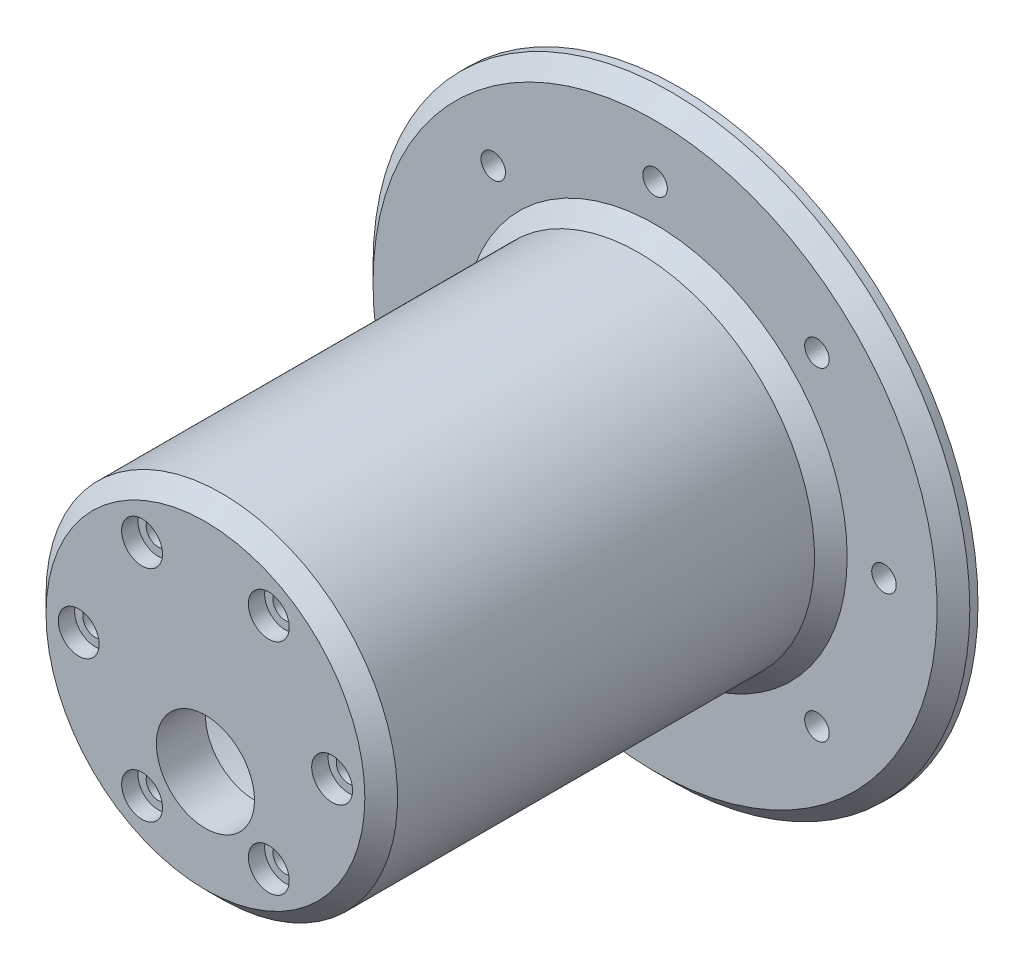
from build123d import *

# Parameters (mm, degrees)
CBORE_FOR_M1_6_HEX_HEAD_CAP_SCREW1_D           = 3
CBORE_FOR_M1_6_HEX_HEAD_CAP_SCREW1_CBORE_D     = 5
CBORE_FOR_M1_6_HEX_HEAD_CAP_SCREW1_CBORE_DEPTH = 2
CIRPATTERN1_COUNT                              = 6
F_12_0MM_DOWEL_HOLE1_D                         = 12
F_12_0MM_DOWEL_HOLE1_DEPTH                     = 15
F_12_0MM_DOWEL_HOLE1_TIP                       = 3.605163714
CHAMFER1_SIZE                                  = 2
CIRPATTERN2_COUNT                              = 8


with BuildPart() as part:
    # Sketch1 → Revolve1 (revolve)
    with BuildSketch(Plane(origin=(0, 0, 0), x_dir=(0, 0, -1), z_dir=(1, 0, 0))):
        Polygon((0, 0), (0, 18.5), (52, 18.5), (52, 23.5), (51, 23.5), (51, 25.5), (52, 25.5), (52, 36.5), (49, 36.5), (49, 21.5), (-6, 21.5), (-6, 0), align=None)
    revolve(axis=Axis((0, 0, 6), (0, 0, -1)))

    # CBORE for M1.6 Hex Head Cap Screw1 (through all)
    with Locations(Plane.XY.offset(6)):
        with Locations((15.5, 0)):
            cbore_for_m1_6_hex_head_cap_screw1 = CounterBoreHole(CBORE_FOR_M1_6_HEX_HEAD_CAP_SCREW1_D / 2, CBORE_FOR_M1_6_HEX_HEAD_CAP_SCREW1_CBORE_D / 2, CBORE_FOR_M1_6_HEX_HEAD_CAP_SCREW1_CBORE_DEPTH)

    # CirPattern1: CBORE for M1.6 Hex Head Cap Screw1 ×6 about axis
    cirpattern1_axis = Axis((0, 0, 0), (0, 0, 1))
    for i in range(1, CIRPATTERN1_COUNT):
        add(cbore_for_m1_6_hex_head_cap_screw1.rotate(cirpattern1_axis, i * 360 / CIRPATTERN1_COUNT), mode=Mode.SUBTRACT)

    # Ø12.0mm Dowel Hole1
    with Locations(Plane.XY.offset(6)):
        with Locations((0, -7)):
            Hole(F_12_0MM_DOWEL_HOLE1_D / 2, depth=F_12_0MM_DOWEL_HOLE1_DEPTH)
            with Locations((0, 0, -(F_12_0MM_DOWEL_HOLE1_DEPTH + F_12_0MM_DOWEL_HOLE1_TIP / 2))):  # 118° drill point
                Cone(0, F_12_0MM_DOWEL_HOLE1_D / 2, F_12_0MM_DOWEL_HOLE1_TIP, mode=Mode.SUBTRACT)

    # Chamfer1
    chamfer1_edges = [part.edges().sort_by_distance(p)[0] for p in [
        (0, -21.5, 6),
        (0, -21.5, -49),
        (0, -36.5, -49),
    ]]
    chamfer(chamfer1_edges, length=CHAMFER1_SIZE)

    # Sketch7 → Ø3.0mm Dowel Hole3 (revolve, cut)
    with BuildSketch(Plane(origin=(0, 28, -49), x_dir=(0, -1, 0), z_dir=(1, 0, 0))):
        Polygon((0, 0), (0, 15.901290929), (1.5, 15), (1.5, 0), align=None)
    f_3_0mm_dowel_hole3 = revolve(axis=Axis((0, 28, -42.65), (0, 0, -1)), mode=Mode.SUBTRACT)

    # CirPattern2: Ø3.0mm Dowel Hole3 ×8 about axis
    cirpattern2_axis = Axis((0, 0, 0), (0, 0, 1))
    for i in range(1, CIRPATTERN2_COUNT):
        add(f_3_0mm_dowel_hole3.rotate(cirpattern2_axis, i * 360 / CIRPATTERN2_COUNT), mode=Mode.SUBTRACT)


solid = part.part
